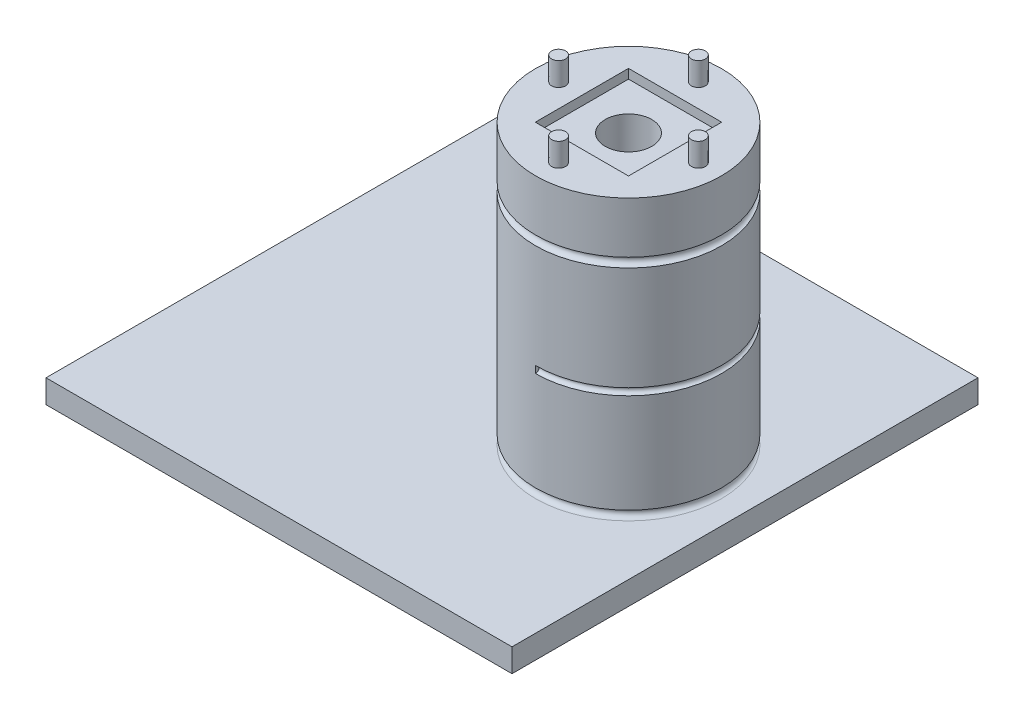
from build123d import *

# Parameters (mm, degrees)
SKETCH2_W                = 100
SKETCH2_H                = 100
BOSS_EXTRUDE1_DEPTH      = 5
SKETCH3_R                = 19.95
BOSS_EXTRUDE2_DEPTH      = 60
SKETCH4_R                = 5
CUT_EXTRUDE1_DEPTH       = 43.5
SKETCH10_R               = 1
SKETCH11_R               = 1
SKETCH15_R               = 5
BOSS_EXTRUDE3_DEPTH      = 10
BOSS_EXTRUDE3_DEPTH_BACK = 2
SKETCH18_R               = 5
BOSS_EXTRUDE4_DEPTH      = 1
SKETCH19_R               = 2.7
CUT_EXTRUDE3_DEPTH       = 36
SKETCH20_R               = 0.75
CUT_REVOLVE4_ANGLE       = 180
SKETCH21_W               = 20
SKETCH21_H               = 20
CUT_EXTRUDE4_DEPTH       = 2
SKETCH23_R               = 1.5
BOSS_EXTRUDE5_DEPTH      = 5


with BuildPart() as part:
    # Sketch2 → Boss-Extrude1 (new body)
    with BuildSketch(Plane(origin=(0, 0, 0), x_dir=(1, 0, 0), z_dir=(0, 1, 0))):
        with Locations((-25, 0)):
            Rectangle(SKETCH2_W, SKETCH2_H)
    extrude(amount=BOSS_EXTRUDE1_DEPTH)

    # Sketch3 → Boss-Extrude2 (add)
    with BuildSketch(Plane(origin=(0, 5, 0), x_dir=(1, 0, 0), z_dir=(0, 1, 0))):
        Circle(SKETCH3_R)
    extrude(amount=BOSS_EXTRUDE2_DEPTH)

    # Sketch4 → Cut-Extrude1 (cut)
    with BuildSketch(Plane(origin=(0, 65, 0), x_dir=(1, 0, 0), z_dir=(0, 1, 0))):
        Circle(SKETCH4_R)
    extrude(amount=-CUT_EXTRUDE1_DEPTH, mode=Mode.SUBTRACT)

    # Sketch10 → Cut-Revolve2 (revolve, cut)
    with BuildSketch(Plane.XY):
        with Locations((19.95, 6)):
            Circle(SKETCH10_R)
    revolve(axis=Axis((0, 0, 0), (0, 1, 0)), mode=Mode.SUBTRACT)

    # Sketch11 → Cut-Revolve3 (revolve, cut)
    with BuildSketch(Plane.XY):
        with Locations((19.95, 53)):
            Circle(SKETCH11_R)
    revolve(axis=Axis((0, 0, 0), (0, 1, 0)), mode=Mode.SUBTRACT)

    # Sketch15 → Boss-Extrude3 (add, two sides)
    with BuildSketch(Plane(origin=(0, 38, 0), x_dir=(1, 0, 0), z_dir=(0, 1, 0))) as boss_extrude3_sk:
        Circle(SKETCH15_R)
    extrude(amount=BOSS_EXTRUDE3_DEPTH)
    extrude(boss_extrude3_sk.sketch, amount=-BOSS_EXTRUDE3_DEPTH_BACK)

    # Sketch18 → Boss-Extrude4 (add)
    with BuildSketch(Plane(origin=(0, 65, 0), x_dir=(1, 0, 0), z_dir=(0, 1, 0))):
        Circle(SKETCH18_R)
    extrude(amount=-BOSS_EXTRUDE4_DEPTH)

    # Sketch19 → Cut-Extrude3 (cut)
    with BuildSketch(Plane(origin=(0, 65, 0), x_dir=(1, 0, 0), z_dir=(0, 1, 0))):
        Circle(SKETCH19_R)
    extrude(amount=-CUT_EXTRUDE3_DEPTH, mode=Mode.SUBTRACT)

    # Sketch20 → Cut-Revolve4 (revolve, cut)
    with BuildSketch(Plane(origin=(0, 0, 0), x_dir=(0, 0, -1), z_dir=(1, 0, 0))):
        with Locations((-19.95, 29)):
            Circle(SKETCH20_R)
    revolve(axis=Axis((0, 0, 0), (0, 1, 0)), revolution_arc=CUT_REVOLVE4_ANGLE, mode=Mode.SUBTRACT)

    # Sketch21 → Cut-Extrude4 (cut)
    with BuildSketch(Plane(origin=(0, 65, 0), x_dir=(1, 0, 0), z_dir=(0, 1, 0))):
        Rectangle(SKETCH21_W, SKETCH21_H)
    extrude(amount=-CUT_EXTRUDE4_DEPTH, mode=Mode.SUBTRACT)

    # Sketch23 → Boss-Extrude5 (add)
    with BuildSketch(Plane(origin=(0, 65, 0), x_dir=(1, 0, 0), z_dir=(0, 1, 0))):
        with Locations((0, -15)):
            Circle(SKETCH23_R)
        with Locations((0, 15)):
            Circle(SKETCH23_R)
        with Locations((-15, 0)):
            Circle(SKETCH23_R)
        with Locations((15, 0)):
            Circle(SKETCH23_R)
    extrude(amount=BOSS_EXTRUDE5_DEPTH)


solid = part.part
